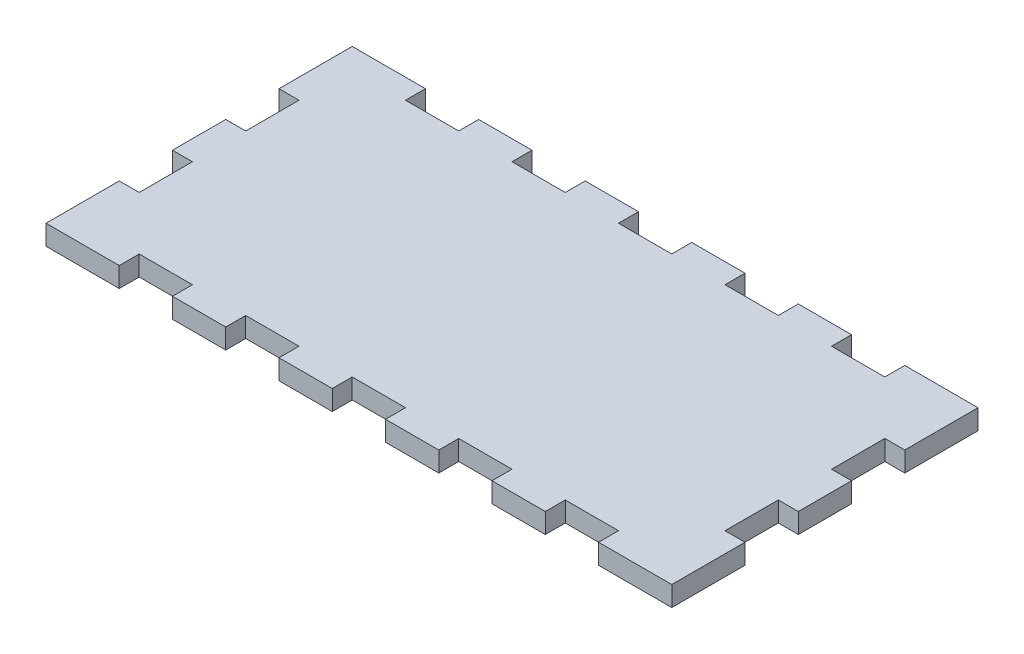
from build123d import *

# Parameters (mm, degrees)
SKETCH2_W               = 279.4
SKETCH2_H               = 127
BOSS_EXTRUDE1_DEPTH     = 9.525
SKETCH3_W               = 25.4
SKETCH3_H               = 9.525
BOSS_EXTRUDE2_DEPTH     = 9.525
LPATTERN1_COUNT         = 6
LPATTERN1_PITCH         = 50.8
MIRROR1_COPY_1_SKETCH_W = 25.4
MIRROR1_COPY_1_SKETCH_H = 9.525
MIRROR1_COPY_1_DEPTH    = 9.525
MIRROR1_COPY_2_SKETCH_W = 25.4
MIRROR1_COPY_2_SKETCH_H = 9.525
MIRROR1_COPY_2_DEPTH    = 9.525
MIRROR1_COPY_3_SKETCH_W = 25.4
MIRROR1_COPY_3_SKETCH_H = 9.525
MIRROR1_COPY_3_DEPTH    = 9.525
MIRROR1_COPY_4_SKETCH_W = 25.4
MIRROR1_COPY_4_SKETCH_H = 9.525
MIRROR1_COPY_4_DEPTH    = 9.525
MIRROR1_COPY_5_SKETCH_W = 25.4
MIRROR1_COPY_5_SKETCH_H = 9.525
MIRROR1_COPY_5_DEPTH    = 9.525
SKETCH4_W               = 25.4
SKETCH4_H               = 9.525
BOSS_EXTRUDE3_DEPTH     = 9.525
LPATTERN2_COUNT         = 3
LPATTERN2_PITCH         = 50.8
MIRROR2_COPY_1_SKETCH_W = 25.4
MIRROR2_COPY_1_SKETCH_H = 9.525
MIRROR2_COPY_1_DEPTH    = 9.525
MIRROR2_COPY_2_SKETCH_W = 25.4
MIRROR2_COPY_2_SKETCH_H = 9.525
MIRROR2_COPY_2_DEPTH    = 9.525
SKETCH6_W               = 9.525
SKETCH6_H               = 9.525
BOSS_EXTRUDE4_DEPTH     = 9.525
MIRROR4_COPY_1_SKETCH_W = 9.525
MIRROR4_COPY_1_SKETCH_H = 9.525
MIRROR4_COPY_1_DEPTH    = 9.525
MIRROR4_COPY_2_SKETCH_W = 9.525
MIRROR4_COPY_2_SKETCH_H = 9.525
MIRROR4_COPY_2_DEPTH    = 9.525


with BuildPart() as part:
    # Sketch2 → Boss-Extrude1 (new body)
    with BuildSketch(Plane(origin=(0, 0, 0), x_dir=(1, 0, 0), z_dir=(0, 1, 0))):
        Rectangle(SKETCH2_W, SKETCH2_H)
    extrude(amount=BOSS_EXTRUDE1_DEPTH)

    # Sketch3 → Boss-Extrude2 (add)
    with BuildSketch(Plane.XY.offset(63.5)):
        with Locations((-127, 4.7625)):
            Rectangle(SKETCH3_W, SKETCH3_H)
    boss_extrude2 = extrude(amount=BOSS_EXTRUDE2_DEPTH)

    # LPattern1: Boss-Extrude2 ×6
    with Locations(*[(i * LPATTERN1_PITCH, 0, 0) for i in range(1, LPATTERN1_COUNT)]):
        add(boss_extrude2)

    # Mirror1: Boss-Extrude2 across plane
    add(boss_extrude2.mirror(Plane.XY))

    # Mirror1 copy 1 sketch → Mirror1 copy 1 (add)
    with BuildSketch(Plane(origin=(50.8, 0, -63.5), x_dir=(1, 0, 0), z_dir=(0, 0, -1))):
        with Locations((-127, -4.7625)):
            Rectangle(MIRROR1_COPY_1_SKETCH_W, MIRROR1_COPY_1_SKETCH_H)
    extrude(amount=MIRROR1_COPY_1_DEPTH)

    # Mirror1 copy 2 sketch → Mirror1 copy 2 (add)
    with BuildSketch(Plane(origin=(101.6, 0, -63.5), x_dir=(1, 0, 0), z_dir=(0, 0, -1))):
        with Locations((-127, -4.7625)):
            Rectangle(MIRROR1_COPY_2_SKETCH_W, MIRROR1_COPY_2_SKETCH_H)
    extrude(amount=MIRROR1_COPY_2_DEPTH)

    # Mirror1 copy 3 sketch → Mirror1 copy 3 (add)
    with BuildSketch(Plane(origin=(152.4, 0, -63.5), x_dir=(1, 0, 0), z_dir=(0, 0, -1))):
        with Locations((-127, -4.7625)):
            Rectangle(MIRROR1_COPY_3_SKETCH_W, MIRROR1_COPY_3_SKETCH_H)
    extrude(amount=MIRROR1_COPY_3_DEPTH)

    # Mirror1 copy 4 sketch → Mirror1 copy 4 (add)
    with BuildSketch(Plane(origin=(203.2, 0, -63.5), x_dir=(1, 0, 0), z_dir=(0, 0, -1))):
        with Locations((-127, -4.7625)):
            Rectangle(MIRROR1_COPY_4_SKETCH_W, MIRROR1_COPY_4_SKETCH_H)
    extrude(amount=MIRROR1_COPY_4_DEPTH)

    # Mirror1 copy 5 sketch → Mirror1 copy 5 (add)
    with BuildSketch(Plane(origin=(254, 0, -63.5), x_dir=(1, 0, 0), z_dir=(0, 0, -1))):
        with Locations((-127, -4.7625)):
            Rectangle(MIRROR1_COPY_5_SKETCH_W, MIRROR1_COPY_5_SKETCH_H)
    extrude(amount=MIRROR1_COPY_5_DEPTH)

    # Sketch4 → Boss-Extrude3 (add)
    with BuildSketch(Plane(origin=(139.7, 0, 0), x_dir=(0, 0, -1), z_dir=(1, 0, 0))):
        with Locations((-50.8, 4.7625)):
            Rectangle(SKETCH4_W, SKETCH4_H)
    boss_extrude3 = extrude(amount=BOSS_EXTRUDE3_DEPTH)

    # LPattern2: Boss-Extrude3 ×3
    with Locations(*[(0, 0, -i * LPATTERN2_PITCH) for i in range(1, LPATTERN2_COUNT)]):
        add(boss_extrude3)

    # Mirror2: Boss-Extrude3 across plane
    add(boss_extrude3.mirror(Plane(origin=(0, 0, 0), x_dir=(0, 0, 1), z_dir=(1, 0, 0))))

    # Mirror2 copy 1 sketch → Mirror2 copy 1 (add)
    with BuildSketch(Plane(origin=(-139.7, 0, -50.8), x_dir=(0, 0, -1), z_dir=(-1, 0, 0))):
        with Locations((-50.8, -4.7625)):
            Rectangle(MIRROR2_COPY_1_SKETCH_W, MIRROR2_COPY_1_SKETCH_H)
    extrude(amount=MIRROR2_COPY_1_DEPTH)

    # Mirror2 copy 2 sketch → Mirror2 copy 2 (add)
    with BuildSketch(Plane(origin=(-139.7, 0, -101.6), x_dir=(0, 0, -1), z_dir=(-1, 0, 0))):
        with Locations((-50.8, -4.7625)):
            Rectangle(MIRROR2_COPY_2_SKETCH_W, MIRROR2_COPY_2_SKETCH_H)
    extrude(amount=MIRROR2_COPY_2_DEPTH)

    # Sketch6 → Boss-Extrude4 (add)
    with BuildSketch(Plane.XY.offset(63.5)):
        with Locations((144.4625, 4.7625)):
            Rectangle(SKETCH6_W, SKETCH6_H)
    boss_extrude4 = extrude(amount=BOSS_EXTRUDE4_DEPTH)

    # Mirror3: Boss-Extrude4 across plane
    add(boss_extrude4.mirror(Plane(origin=(0, 0, 0), x_dir=(0, 0, 1), z_dir=(1, 0, 0))))

    # Mirror4 copy 1 sketch → Mirror4 copy 1 (add)
    with BuildSketch(Plane(origin=(0, 0, -63.5), x_dir=(-1, 0, 0), z_dir=(0, 0, -1))):
        with Locations((144.4625, 4.7625)):
            Rectangle(MIRROR4_COPY_1_SKETCH_W, MIRROR4_COPY_1_SKETCH_H)
    extrude(amount=MIRROR4_COPY_1_DEPTH)

    # Mirror4 copy 2 sketch → Mirror4 copy 2 (add)
    with BuildSketch(Plane(origin=(0, 0, -63.5), x_dir=(1, 0, 0), z_dir=(0, 0, -1))):
        with Locations((144.4625, -4.7625)):
            Rectangle(MIRROR4_COPY_2_SKETCH_W, MIRROR4_COPY_2_SKETCH_H)
    extrude(amount=MIRROR4_COPY_2_DEPTH)


solid = part.part
